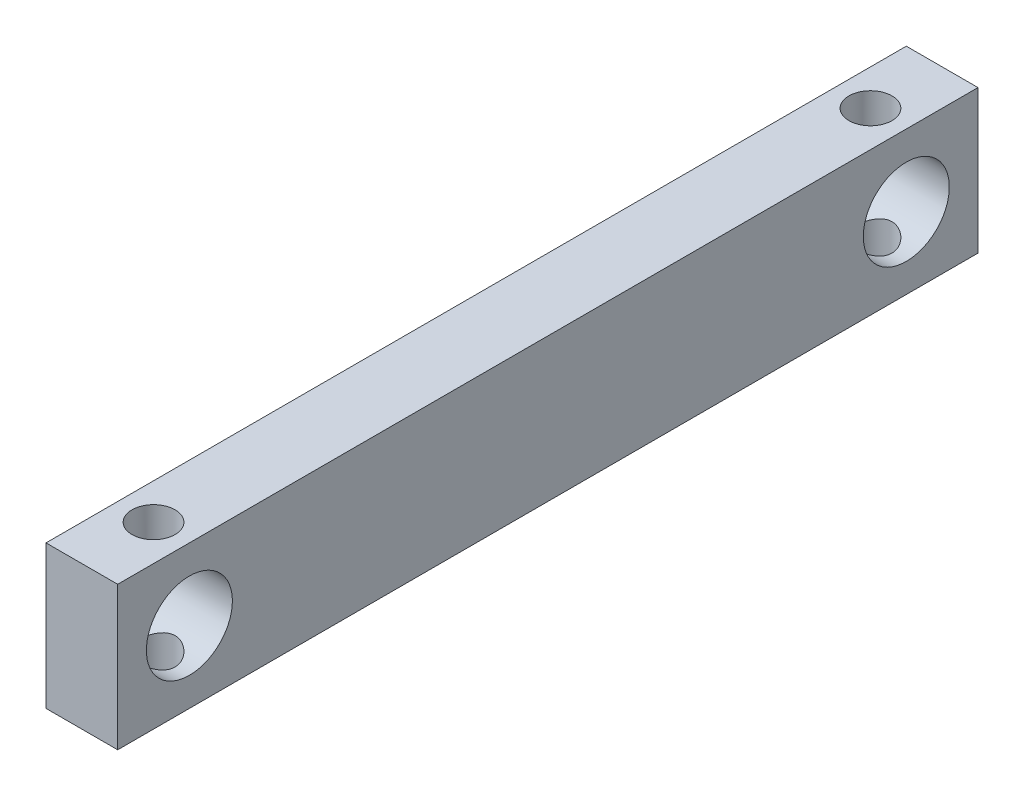
from build123d import *

# Parameters (mm, degrees)
SKETCH_1_W               = 60
SKETCH_1_H               = 10
SKETCH_1_R               = 3
EXTRUDE_1_DEPTH          = 2.5
SKETCH_3_R               = 1.5
CUT_EXTRUDE_1_DEPTH      = 6
CUT_EXTRUDE_1_DEPTH_BACK = 6


with BuildPart() as part:
    # 草圖1 → 填料-伸長1 (new body, symmetric)
    with BuildSketch(Plane(origin=(0, 0, 0), x_dir=(0, 0, -1), z_dir=(1, 0, 0))):
        Rectangle(SKETCH_1_W, SKETCH_1_H)
        with Locations((-25, 0)):
            Circle(SKETCH_1_R, mode=Mode.SUBTRACT)
        with Locations((25, 0)):
            Circle(SKETCH_1_R, mode=Mode.SUBTRACT)
    extrude(amount=EXTRUDE_1_DEPTH, both=True)

    # 草圖3 → 除料-伸長1 (cut, two sides)
    with BuildSketch(Plane(origin=(0, 0, 0), x_dir=(1, 0, 0), z_dir=(0, 1, 0))) as cut_extrude_1_sk:
        with Locations((0, 25)):
            Circle(SKETCH_3_R)
        with Locations((0, -25)):
            Circle(SKETCH_3_R)
    extrude(amount=CUT_EXTRUDE_1_DEPTH, mode=Mode.SUBTRACT)
    extrude(cut_extrude_1_sk.sketch, amount=-CUT_EXTRUDE_1_DEPTH_BACK, mode=Mode.SUBTRACT)


solid = part.part
